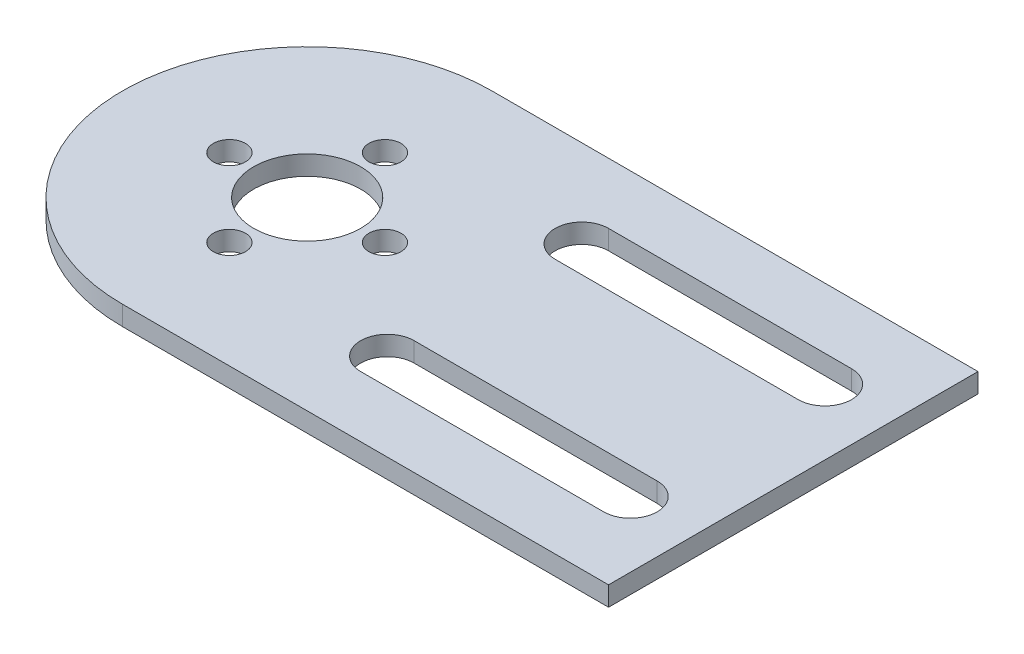
from build123d import *

# Parameters (mm, degrees)
EXTRUDE_1_DEPTH     = 2
SKETCH_2_R          = 5.5
SKETCH_2_R_2        = 1.65
CUT_EXTRUDE_1_DEPTH = 3


with BuildPart() as part:
    # 草图1 → 凸台-拉伸1 (new body)
    with BuildSketch(Plane(origin=(0, 0, 0), x_dir=(1, 0, 0), z_dir=(0, 1, 0))):
        with BuildLine():
            Line((0, 19), (50, 19))
            Line((50, 19), (50, -19))
            Line((50, -19), (0, -19))
            ThreePointArc((0, -19), (-19, 0), (0, 19))
        make_face()
    extrude(amount=EXTRUDE_1_DEPTH)

    # 草图2 → 切除-拉伸1 (cut, through all)
    with BuildSketch(Plane(origin=(0, 2, 0), x_dir=(1, 0, 0), z_dir=(0, 1, 0))):
        Circle(SKETCH_2_R)
        with Locations((0, -8)):
            Circle(SKETCH_2_R_2)
        with Locations((-8, 0)):
            Circle(SKETCH_2_R_2)
        with Locations((0, 8)):
            Circle(SKETCH_2_R_2)
        with Locations((8, 0)):
            Circle(SKETCH_2_R_2)
        with BuildLine():
            Line((18.25, 12.75), (43.25, 12.75))
            ThreePointArc((43.25, 12.75), (46, 10), (43.25, 7.25))
            Line((43.25, 7.25), (18.25, 7.25))
            ThreePointArc((18.25, 7.25), (15.5, 10), (18.25, 12.75))
        make_face()
        with BuildLine():
            Line((43.25, -7.25), (18.25, -7.25))
            ThreePointArc((18.25, -7.25), (15.5, -10), (18.25, -12.75))
            Line((18.25, -12.75), (43.25, -12.75))
            ThreePointArc((43.25, -12.75), (46, -10), (43.25, -7.25))
        make_face()
    extrude(amount=-CUT_EXTRUDE_1_DEPTH, mode=Mode.SUBTRACT)


solid = part.part
